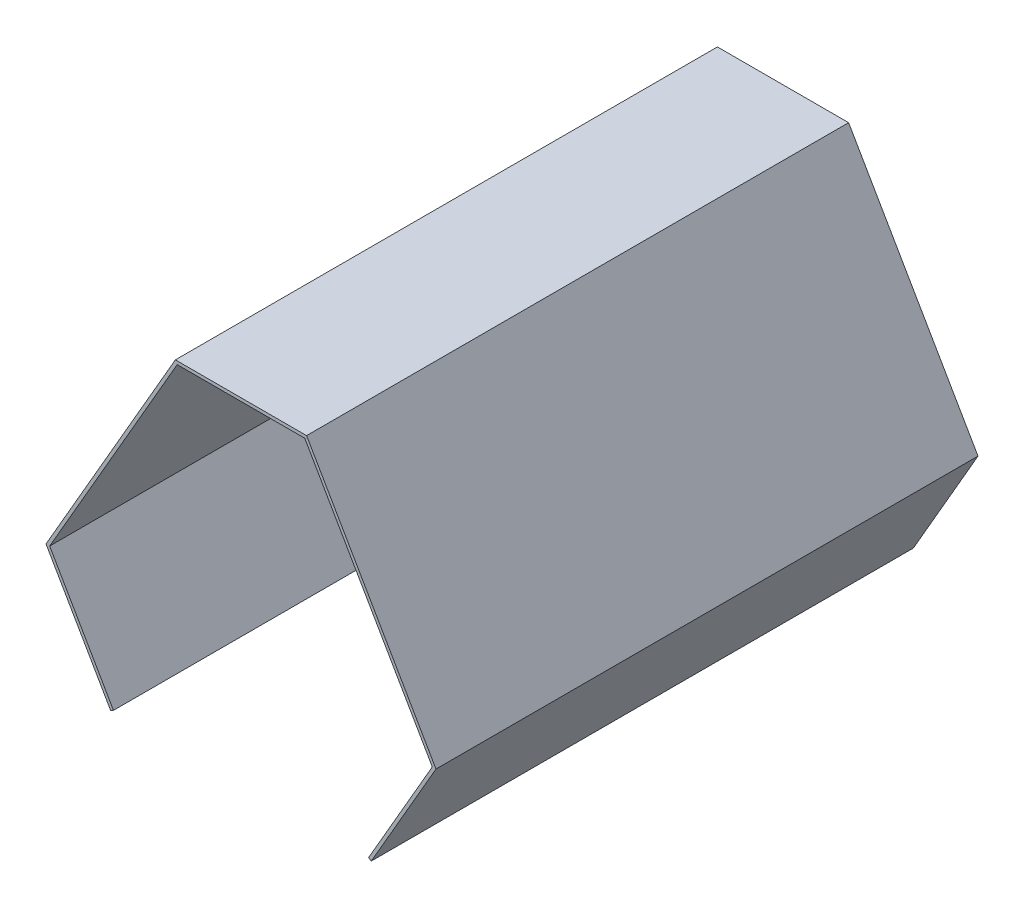
from build123d import *

# Parameters (mm, degrees)
BOSS_EXTRUDE1_DEPTH = 850


with BuildPart() as part:
    # Sketch1 → Boss-Extrude1 (new body)
    with BuildSketch(Plane.XY):
        Polygon((-100, 259.807621), (100, 259.807621), (300, -86.602540514), (200, -259.807621271), (204.330127019, -262.307621271), (305.773502692, -86.602540514), (102.886751346, 264.807621), (-102.886751346, 264.807621), (-305.773502692, -86.602540514), (-204.330127019, -262.307621271), (-200, -259.807621271), (-300, -86.602540514), align=None)
    extrude(amount=BOSS_EXTRUDE1_DEPTH)


solid = part.part
